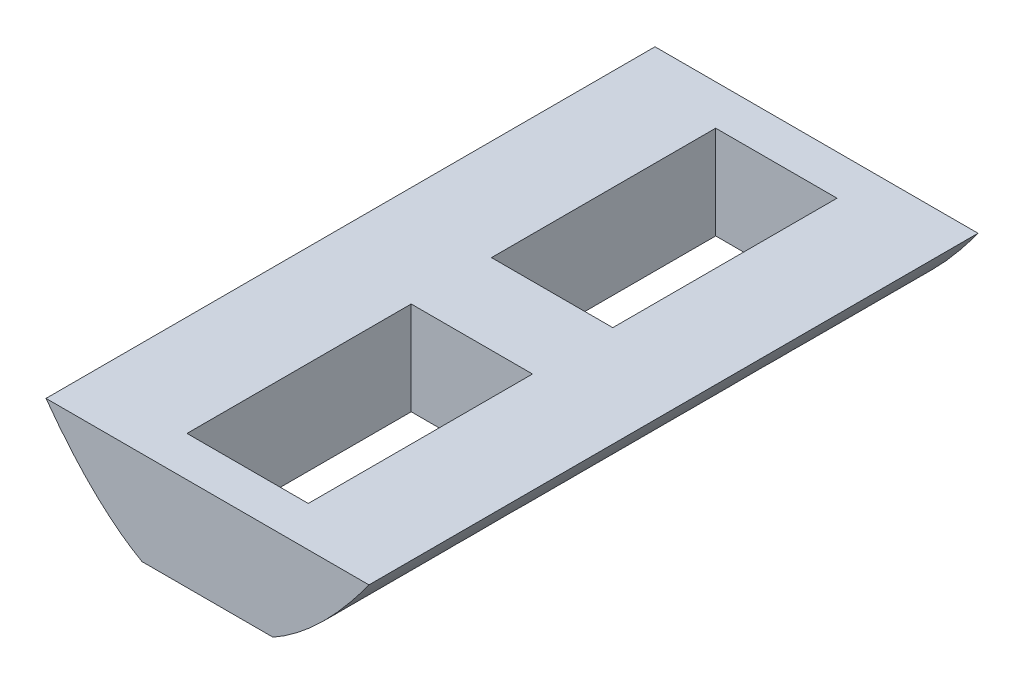
from build123d import *

# Parameters (mm, degrees)
BOSS_EXTRUDE2_DEPTH = 331.382
SKETCH3_W           = 66
SKETCH3_H           = 122
CUT_EXTRUDE2_DEPTH  = 128.0000001
SKETCH4_W           = 80
SKETCH4_H           = 10
CUT_EXTRUDE3_DEPTH  = 332.3820001
SKETCH5_W           = 260
SKETCH5_H           = 70
CUT_EXTRUDE4_DEPTH  = 332.3820001


with BuildPart() as part:
    # Sketch2 → Boss-Extrude2 (new body)
    with BuildSketch(Plane.XY):
        with BuildLine():
            Line((-127, 127), (127, 127))
            add(Edge.make_bspline(
                [(-127, 127), (0, -127), (127, 127)],
                knots=[0.056028396, 0.056028396, 0.056028396, 0.943971604, 0.943971604, 0.943971604], degree=2))
        make_face()
    extrude(amount=BOSS_EXTRUDE2_DEPTH)

    # Sketch3 → Cut-Extrude2 (cut, through all)
    with BuildSketch(Plane(origin=(0, 127, 0), x_dir=(1, 0, 0), z_dir=(0, 1, 0))):
        with Locations((0, -82.8455)):
            Rectangle(SKETCH3_W, SKETCH3_H)
        with Locations((0, -248.5365)):
            Rectangle(SKETCH3_W, SKETCH3_H)
    extrude(amount=-CUT_EXTRUDE2_DEPTH, mode=Mode.SUBTRACT)

    # Sketch4 → Cut-Extrude3 (cut, through all)
    with BuildSketch(Plane(origin=(0, 0, 0), x_dir=(-1, 0, 0), z_dir=(0, 0, -1))):
        with Locations((0, 5)):
            Rectangle(SKETCH4_W, SKETCH4_H)
    extrude(amount=-CUT_EXTRUDE3_DEPTH, mode=Mode.SUBTRACT)

    # Sketch5 → Cut-Extrude4 (cut, through all)
    with BuildSketch(Plane.XY.offset(331.382)):
        with Locations((0, 95.8)):
            Rectangle(SKETCH5_W, SKETCH5_H)
    extrude(amount=-CUT_EXTRUDE4_DEPTH, mode=Mode.SUBTRACT)


solid = part.part
